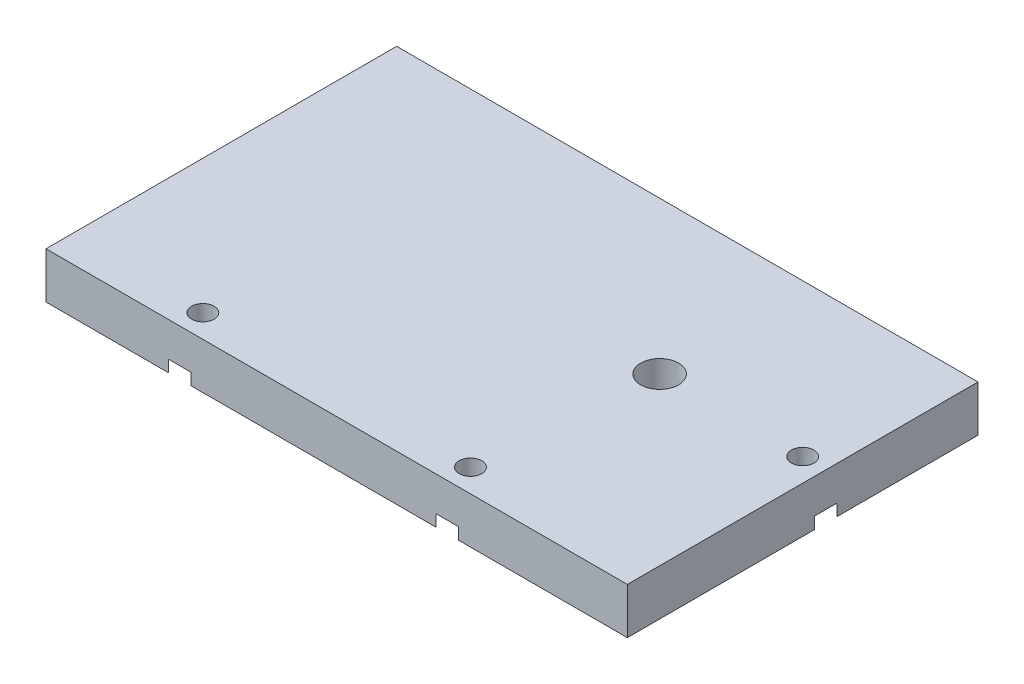
from build123d import *

# Parameters (mm, degrees)
SKETCH1_W                                           = 63
SKETCH1_H                                           = 38
BOSS_EXTRUDE1_DEPTH                                 = 5
CBORE_FOR_2_BINDING_HEAD_MACHINE_SCREW2_D           = 2.4384
CBORE_FOR_2_BINDING_HEAD_MACHINE_SCREW2_CBORE_D     = 5.55752
CBORE_FOR_2_BINDING_HEAD_MACHINE_SCREW2_CBORE_DEPTH = 1.27
CBORE_FOR_2_BINDING_HEAD_MACHINE_SCREW3_D           = 2.4384
CBORE_FOR_2_BINDING_HEAD_MACHINE_SCREW3_CBORE_D     = 5.55752
CBORE_FOR_2_BINDING_HEAD_MACHINE_SCREW3_CBORE_DEPTH = 1.27
CUT_EXTRUDE1_DEPTH                                  = 10
F_2_56_TAPPED_HOLE2_D                               = 1.778
F_2_56_TAPPED_HOLE2_DEPTH                           = 2.46583491
F_2_56_TAPPED_HOLE2_TIP                             = 0.53416509
F_2_56_TAPPED_HOLE3_D                               = 1.778
F_2_56_TAPPED_HOLE3_DEPTH                           = 7.46583491
F_2_56_TAPPED_HOLE3_TIP                             = 0.53416509


with BuildPart() as part:
    # Sketch1 → Boss-Extrude1 (new body)
    with BuildSketch(Plane(origin=(0, 0, 0), x_dir=(1, 0, 0), z_dir=(0, 1, 0))):
        Rectangle(SKETCH1_W, SKETCH1_H)
    extrude(amount=BOSS_EXTRUDE1_DEPTH)

    # CBORE for #2 Binding Head Machine Screw2 (through all)
    with Locations(Plane(origin=(0, 0, 0), x_dir=(-1, 0, 0), z_dir=(0, -1, 0))):
        with Locations((-29, 2.5)):
            CounterBoreHole(CBORE_FOR_2_BINDING_HEAD_MACHINE_SCREW2_D / 2, CBORE_FOR_2_BINDING_HEAD_MACHINE_SCREW2_CBORE_D / 2, CBORE_FOR_2_BINDING_HEAD_MACHINE_SCREW2_CBORE_DEPTH)

    # CBORE for #2 Binding Head Machine Screw3 (through all)
    with Locations(Plane(origin=(0, 0, 0), x_dir=(-1, 0, 0), z_dir=(0, -1, 0))):
        with Locations((-12, -16.5), (17, -16.5)):
            CounterBoreHole(CBORE_FOR_2_BINDING_HEAD_MACHINE_SCREW3_D / 2, CBORE_FOR_2_BINDING_HEAD_MACHINE_SCREW3_CBORE_D / 2, CBORE_FOR_2_BINDING_HEAD_MACHINE_SCREW3_CBORE_DEPTH)

    # Sketch17 → Cut-Extrude1 (cut)
    with BuildSketch(Plane.XZ):
        with BuildLine():
            ThreePointArc((15.55, -2.5), (14.949568901, -1.050431099), (13.5, -0.45))
            Line((13.5, -0.45), (13.5, -2.5))
            Line((13.5, -2.5), (13.5, -4.55))
            ThreePointArc((13.5, -4.55), (14.949568901, -3.949568901), (15.55, -2.5))
        make_face()
        with BuildLine():
            Line((13.5, -2.5), (13.5, -0.45))
            ThreePointArc((13.5, -0.45), (11.45, -2.5), (13.5, -4.55))
            Line((13.5, -4.55), (13.5, -2.5))
        make_face()
    extrude(amount=-CUT_EXTRUDE1_DEPTH, mode=Mode.SUBTRACT)

    # #2-56 Tapped Hole2
    with Locations(Plane(origin=(0, 0, 0), x_dir=(-1, 0, 0), z_dir=(0, -1, 0))):
        with Locations((-13.5, 8.6), (-13.5, -3.6)):
            Hole(F_2_56_TAPPED_HOLE2_D / 2, depth=F_2_56_TAPPED_HOLE2_DEPTH)
            with Locations((0, 0, -(F_2_56_TAPPED_HOLE2_DEPTH + F_2_56_TAPPED_HOLE2_TIP / 2))):  # 118° drill point
                Cone(0, F_2_56_TAPPED_HOLE2_D / 2, F_2_56_TAPPED_HOLE2_TIP, mode=Mode.SUBTRACT)

    # #2-56 Tapped Hole3
    with Locations(Plane(origin=(0, 0, -19), x_dir=(-1, 0, 0), z_dir=(0, 0, -1))):
        with Locations((-12, 2.5), (17, 2.5)):
            Hole(F_2_56_TAPPED_HOLE3_D / 2, depth=F_2_56_TAPPED_HOLE3_DEPTH)
            with Locations((0, 0, -(F_2_56_TAPPED_HOLE3_DEPTH + F_2_56_TAPPED_HOLE3_TIP / 2))):  # 118° drill point
                Cone(0, F_2_56_TAPPED_HOLE3_D / 2, F_2_56_TAPPED_HOLE3_TIP, mode=Mode.SUBTRACT)


solid = part.part
